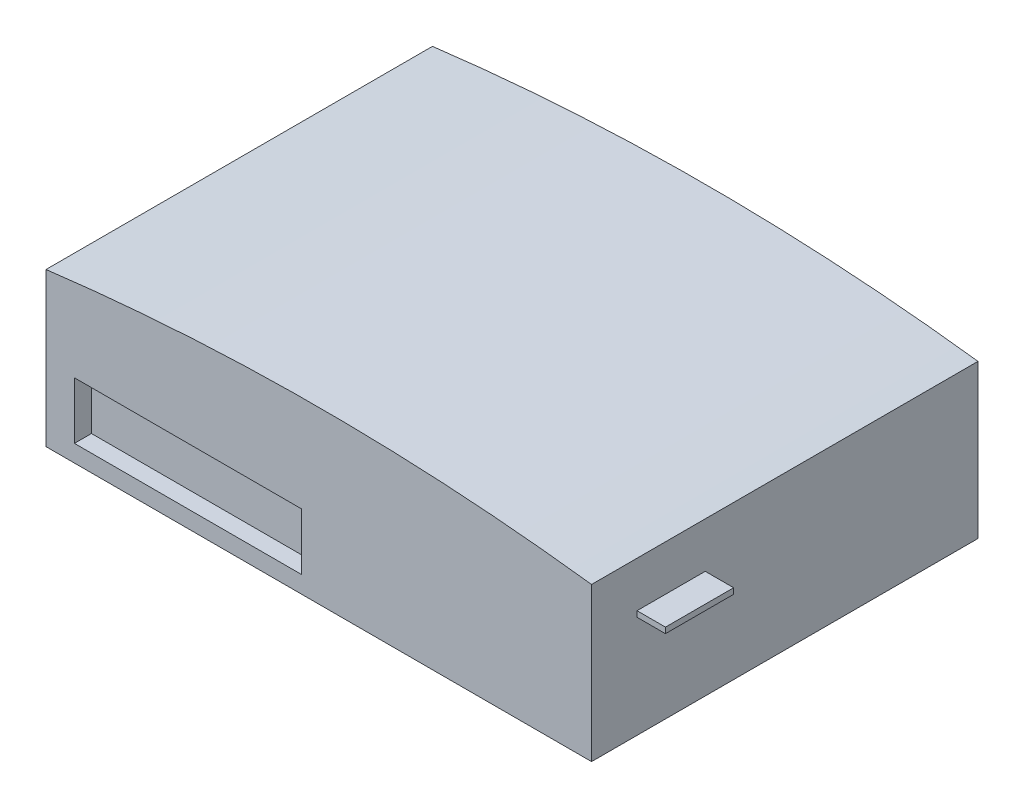
from build123d import *

# Parameters (mm, degrees)
SKETCH1_W           = 96
SKETCH1_H           = 68
BOSS_EXTRUDE1_DEPTH = 30
CUT_EXTRUDE1_DEPTH  = 89.475985442
SKETCH3_W           = 40
SKETCH3_H           = 10
CUT_EXTRUDE2_DEPTH  = 3
SKETCH4_W           = 12
SKETCH4_H           = 1
BOSS_EXTRUDE2_DEPTH = 5
SKETCH5_R           = 2.8
SKETCH5_R_2         = 1.5
CUT_EXTRUDE3_DEPTH  = 2.2
SKETCH5_2_R         = 1.5
CUT_EXTRUDE4_DEPTH  = 10


with BuildPart() as part:
    # Sketch1 → Boss-Extrude1 (new body)
    with BuildSketch(Plane(origin=(0, 0, 0), x_dir=(1, 0, 0), z_dir=(0, 1, 0))):
        Rectangle(SKETCH1_W, SKETCH1_H)
    extrude(amount=BOSS_EXTRUDE1_DEPTH)

    # Sketch2 → Cut-Extrude1 (cut, through all)
    with BuildSketch(Plane.XY.offset(34)):
        with BuildLine():
            Line((-48, 27), (-48, 41.348675948))
            Line((-48, 41.348675948), (48, 41.348675948))
            Line((48, 41.348675948), (48, 27))
            ThreePointArc((48, 27), (0, 30), (-48, 27))
        make_face()
    extrude(amount=-CUT_EXTRUDE1_DEPTH, mode=Mode.SUBTRACT)

    # Sketch3 → Cut-Extrude2 (cut)
    with BuildSketch(Plane.XY.offset(34)):
        with Locations((-23, 8)):
            Rectangle(SKETCH3_W, SKETCH3_H)
    extrude(amount=-CUT_EXTRUDE2_DEPTH, mode=Mode.SUBTRACT)

    # Sketch4 → Boss-Extrude2 (add)
    with BuildSketch(Plane(origin=(48, 0, 0), x_dir=(0, 0, -1), z_dir=(1, 0, 0))):
        with Locations((-20, 18.5)):
            Rectangle(SKETCH4_W, SKETCH4_H)
    extrude(amount=BOSS_EXTRUDE2_DEPTH)

    # Sketch5 → Cut-Extrude3 (cut)
    # profile 1 of 4: a face of its own
    with BuildSketch(Plane.XZ):
        with Locations((-38, 24)):
            Circle(SKETCH5_R)
        with Locations((-38, 24)):
            Circle(SKETCH5_R_2, mode=Mode.SUBTRACT)
    # profile 2 of 4: a face of its own
    with BuildSketch(Plane.XZ):
        with Locations((20, 24)):
            Circle(SKETCH5_R)
        with Locations((20, 24)):
            Circle(SKETCH5_R_2, mode=Mode.SUBTRACT)
    # profile 3 of 4: a face of its own
    with BuildSketch(Plane.XZ):
        with Locations((20, -25)):
            Circle(SKETCH5_R)
        with Locations((20, -25)):
            Circle(SKETCH5_R_2, mode=Mode.SUBTRACT)
    # profile 4 of 4: a face of its own
    with BuildSketch(Plane.XZ):
        with Locations((-38, -25)):
            Circle(SKETCH5_R)
        with Locations((-38, -25)):
            Circle(SKETCH5_R_2, mode=Mode.SUBTRACT)
    extrude(amount=-CUT_EXTRUDE3_DEPTH, mode=Mode.SUBTRACT)

    # Sketch5_2 → Cut-Extrude4 (cut)
    with BuildSketch(Plane.XZ):
        with Locations((-38, 24)):
            Circle(SKETCH5_2_R)
        with Locations((20, 24)):
            Circle(SKETCH5_2_R)
        with Locations((20, -25)):
            Circle(SKETCH5_2_R)
        with Locations((-38, -25)):
            Circle(SKETCH5_2_R)
    extrude(amount=-CUT_EXTRUDE4_DEPTH, mode=Mode.SUBTRACT)


solid = part.part
